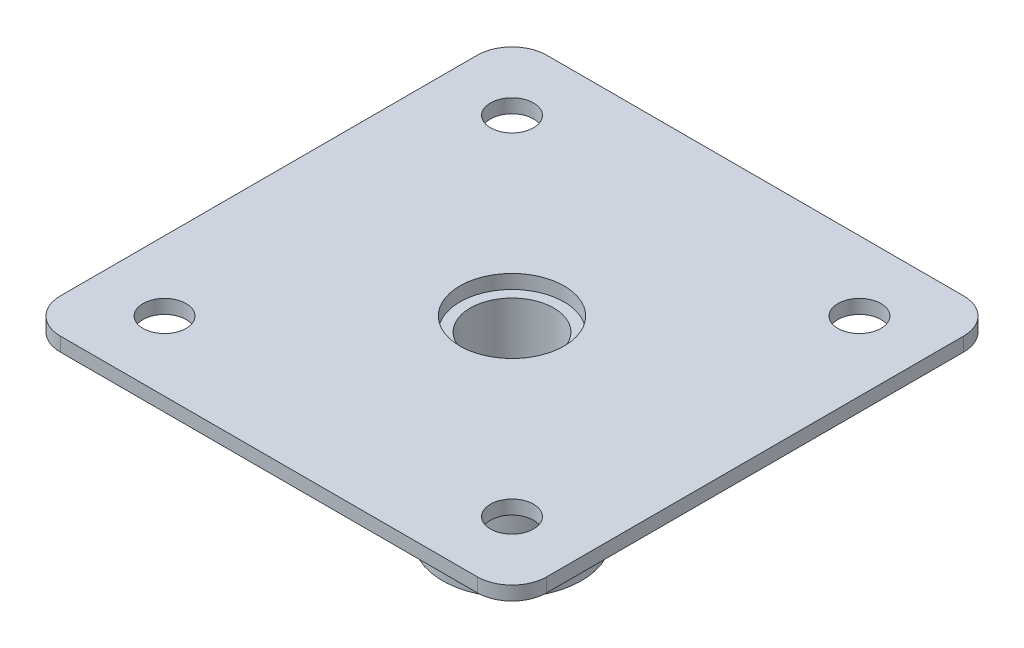
from build123d import *

# Parameters (mm, degrees)
SKETCH1_W           = 70
SKETCH1_H           = 70
SKETCH1_R           = 3.1
BOSS_EXTRUDE1_DEPTH = 2
FILLET1_R           = 5
SKETCH2_R           = 10
BOSS_EXTRUDE2_DEPTH = 26
SKETCH5_R           = 6
CUT_EXTRUDE1_DEPTH  = 29
SKETCH6_R           = 7.5
CUT_EXTRUDE2_DEPTH  = 2


with BuildPart() as part:
    # Sketch1 → Boss-Extrude1 (new body)
    with BuildSketch(Plane(origin=(0, 0, 0), x_dir=(1, 0, 0), z_dir=(0, 1, 0))):
        Rectangle(SKETCH1_W, SKETCH1_H)
        with Locations((25, 25)):
            Circle(SKETCH1_R, mode=Mode.SUBTRACT)
        with Locations((-25, -25)):
            Circle(SKETCH1_R, mode=Mode.SUBTRACT)
        with Locations((-25, 25)):
            Circle(SKETCH1_R, mode=Mode.SUBTRACT)
        with Locations((25, -25)):
            Circle(SKETCH1_R, mode=Mode.SUBTRACT)
    extrude(amount=BOSS_EXTRUDE1_DEPTH)

    # Fillet1
    fillet1_edges = [part.edges().sort_by_distance(p)[0] for p in [
        (35, 1, 35),
        (-35, 1, 35),
        (-35, 1, -35),
        (35, 1, -35),
    ]]
    fillet(fillet1_edges, radius=FILLET1_R)

    # Sketch2 → Boss-Extrude2 (add)
    with BuildSketch(Plane.XZ):
        Circle(SKETCH2_R)
    extrude(amount=BOSS_EXTRUDE2_DEPTH)

    # Sketch5 → Cut-Extrude1 (cut, through all)
    with BuildSketch(Plane.XZ.offset(26)):
        Circle(SKETCH5_R)
    extrude(amount=-CUT_EXTRUDE1_DEPTH, mode=Mode.SUBTRACT)

    # Sketch6 → Cut-Extrude2 (cut)
    with BuildSketch(Plane(origin=(0, 2, 0), x_dir=(1, 0, 0), z_dir=(0, 1, 0))):
        Circle(SKETCH6_R)
    extrude(amount=-CUT_EXTRUDE2_DEPTH, mode=Mode.SUBTRACT)


solid = part.part
